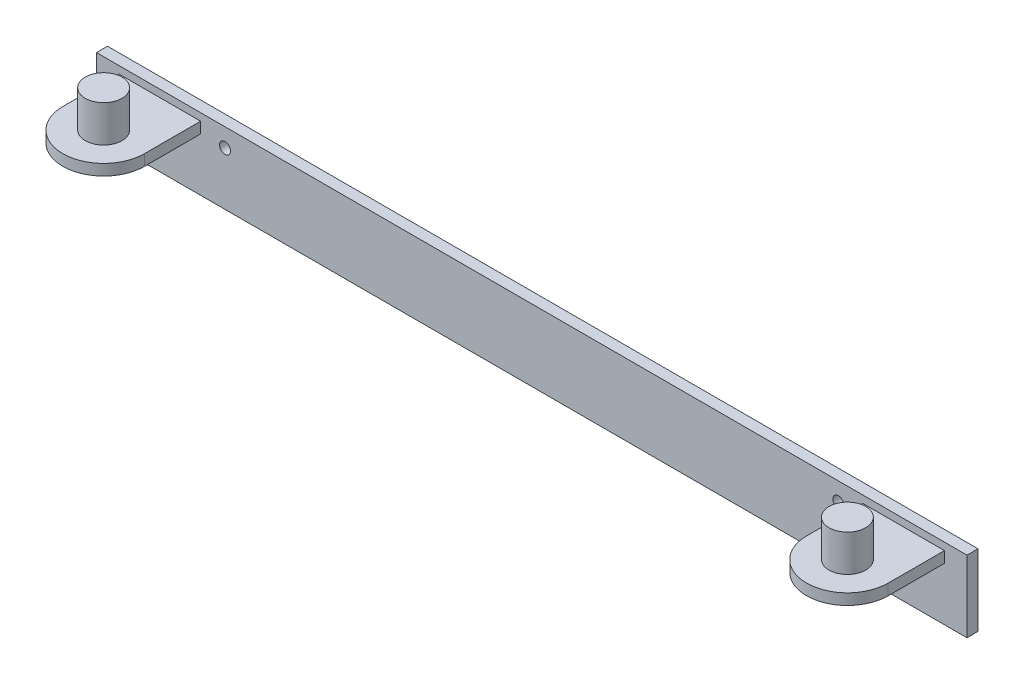
from build123d import *

# Parameters (mm, degrees)
ESQUISSE1_W             = 237.01
ESQUISSE1_H             = 19.49
BOSS_EXTRU_1_DEPTH      = 3
BOSS_EXTRU_2_DEPTH      = 3
ESQUISSE3_R             = 5
BOSS_EXTRU_3_DEPTH      = 10
ESQUISSE4_R             = 5
BOSS_EXTRU_4_DEPTH      = 10
ESQUISSE5_R             = 1.5
ENL_V_MAT_EXTRU_1_DEPTH = 10


with BuildPart() as part:
    # Esquisse1 → Boss.-Extru.1 (new body)
    with BuildSketch(Plane.XY):
        with Locations((59.527989935, 3.140717464)):
            Rectangle(ESQUISSE1_W, ESQUISSE1_H)
    extrude(amount=BOSS_EXTRU_1_DEPTH)

    # Esquisse2 → Boss.-Extru.2 (add)
    with BuildSketch(Plane(origin=(0, 10.885717464, 0), x_dir=(-1, 0, 0), z_dir=(0, 1, 0))):
        with BuildLine():
            Line((52.842010065, 3), (52.842010065, 18.31))
            ThreePointArc((52.842010065, 18.31), (41.727010065, 29.425), (30.612010065, 18.31))
            Line((30.612010065, 18.31), (30.612010065, 3))
            Line((30.612010065, 3), (52.842010065, 3))
        make_face()
        with BuildLine():
            Line((-171.897989935, 3), (-149.667989935, 3))
            Line((-149.667989935, 3), (-149.667989935, 18.31))
            ThreePointArc((-149.667989935, 18.31), (-160.782989935, 29.425), (-171.897989935, 18.31))
            Line((-171.897989935, 18.31), (-171.897989935, 3))
        make_face()
    extrude(amount=-BOSS_EXTRU_2_DEPTH)

    # Esquisse3 → Boss.-Extru.3 (add)
    with BuildSketch(Plane(origin=(0, 10.885717464, 0), x_dir=(-1, 0, 0), z_dir=(0, 1, 0))):
        with Locations((41.727010065, 18.31)):
            Circle(ESQUISSE3_R)
    extrude(amount=BOSS_EXTRU_3_DEPTH)

    # Esquisse4 → Boss.-Extru.4 (add)
    with BuildSketch(Plane(origin=(0, 10.885717464, 0), x_dir=(-1, 0, 0), z_dir=(0, 1, 0))):
        with Locations((-160.782989935, 18.31)):
            Circle(ESQUISSE4_R)
    extrude(amount=BOSS_EXTRU_4_DEPTH)

    # Esquisse5 → Enlèv. mat.-Extru.1 (cut)
    with BuildSketch(Plane.XY.offset(3)):
        with Locations((-23.977010065, 7.885717464)):
            Circle(ESQUISSE5_R)
        with Locations((143.032989935, 7.885717464)):
            Circle(ESQUISSE5_R)
    extrude(amount=-ENL_V_MAT_EXTRU_1_DEPTH, mode=Mode.SUBTRACT)


solid = part.part
